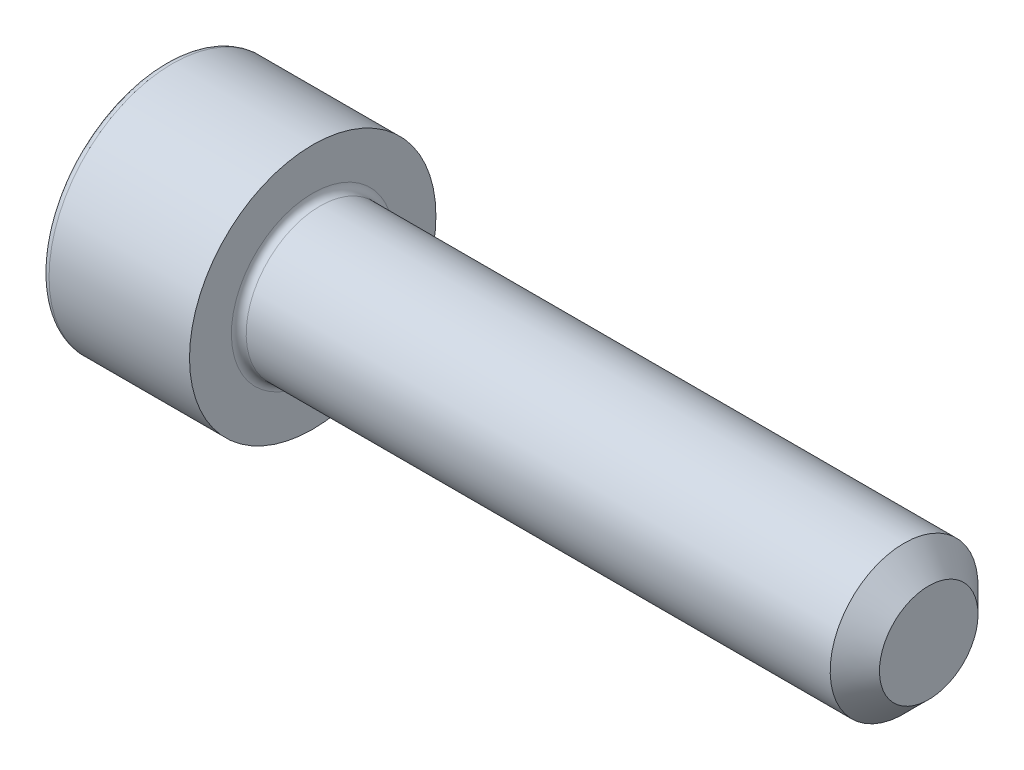
from build123d import *

# Parameters (mm, degrees)
CUT_EXTRUDE_1_DEPTH = 2.5
FILLET_1_R          = 0.3
CHAMFER_1_SIZE      = 1


with BuildPart() as part:
    # Эскиз1 → Повернуть1 (revolve)
    with BuildSketch(Plane.XY):
        Polygon((0, 0), (0, 5), (6, 5), (6, 3), (31, 3), (31, 0), align=None)
    revolve(axis=Axis((31, 0, 0), (-1, 0, 0)))

    # Эскиз2 → Вырез-Вытянуть1 (cut)
    with BuildSketch(Plane.ZY):
        Polygon((-1.443375673, 2.5), (-2.886751346, 0), (-1.443375673, -2.5), (1.443375673, -2.5), (2.886751346, 0), (1.443375673, 2.5), align=None)
    extrude(amount=-CUT_EXTRUDE_1_DEPTH, mode=Mode.SUBTRACT)

    # Скругление1
    fillet_1_edges = [part.edges().sort_by_distance(p)[0] for p in [
        (6, -3, 0),
        (0, -5, 0),
    ]]
    fillet(fillet_1_edges, radius=FILLET_1_R)

    # Фаска1
    chamfer_1_edges = [part.edges().sort_by_distance(p)[0] for p in [
        (31, -3, 0),
    ]]
    chamfer(chamfer_1_edges, length=CHAMFER_1_SIZE)


solid = part.part
